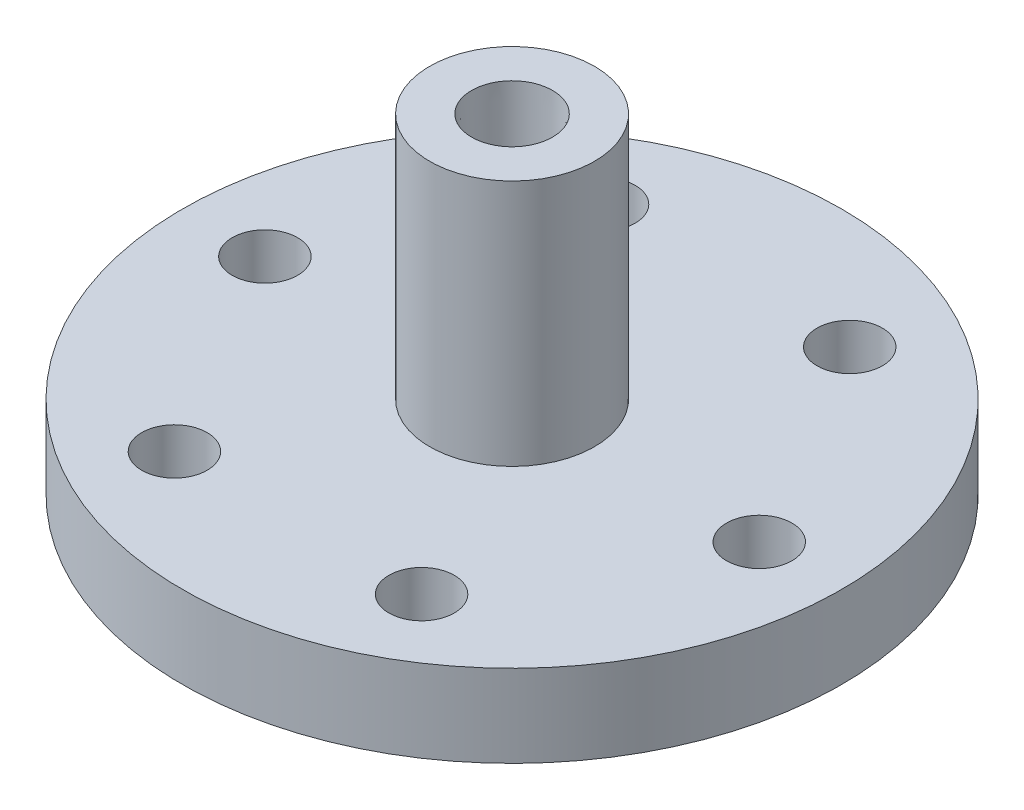
from build123d import *

# Parameters (mm, degrees)
F_3_8_CLEARANCE_HOLE1_D              = 10.0838
CIRPATTERN1_COUNT                    = 6
F_1_32_0_03125_DIAMETER_HOLE1_REACH  = 133.807
F_1_32_0_03125_DIAMETER_HOLE1_BORE_R = 0.396875
F_1_4_0_25_DIAMETER_HOLE1_D          = 6.35
F_1_4_0_25_DIAMETER_HOLE1_DEPTH      = 12.7
F_1_4_0_25_DIAMETER_HOLE1_TIP        = 1.907732465


with BuildPart() as part:
    # Sketch1 → Revolve1 (revolve)
    with BuildSketch(Plane.XY, mode=Mode.PRIVATE) as revolve1_sk:
        Polygon((0, 0), (-12.7, 0), (-12.7, -38.1), (-50.8, -38.1), (-50.8, -50.8), (-13.081, -50.8), (-13.081, -48.26), (-9.525, -48.26), (-9.525, -50.8), (0, -50.8), align=None)
    revolve(revolve1_sk.sketch.rotate(Axis((0, -50.8, 0), (0, 1, 0)), 270), axis=Axis((0, -50.8, 0), (0, 1, 0)))

    # Sketch4 → 1_4 NPT Tapped Hole1 (revolve, cut)
    with BuildSketch(Plane(origin=(0, 0, 0), x_dir=(0, 0, 1), z_dir=(1, 0, 0))):
        Polygon((0, 0), (0, 50.8), (5.5626, 50.8), (5.5626, 9.906), (5.943685794, 9.906), (6.2402847, 0), align=None)
    revolve(axis=Axis((0, 6.35, 0), (0, -1, 0)), mode=Mode.SUBTRACT)

    # 3_8 Clearance Hole1 (through all)
    with Locations(Plane(origin=(0, -38.1, 0), x_dir=(1, 0, 0), z_dir=(0, 1, 0))):
        with Locations((38.1, 0)):
            f_3_8_clearance_hole1 = Hole(F_3_8_CLEARANCE_HOLE1_D / 2)

    # CirPattern1: 3_8 Clearance Hole1 ×6 about axis
    cirpattern1_axis = Axis((0, 0, 0), (0, 1, 0))
    for i in range(1, CIRPATTERN1_COUNT):
        add(f_3_8_clearance_hole1.rotate(cirpattern1_axis, i * 360 / CIRPATTERN1_COUNT), mode=Mode.SUBTRACT)

    # 1_32 _0.03125_ Diameter Hole1 bore → 1_32 _0.03125_ Diameter Hole1 (cut, up to next)
    with BuildSketch(Plane(origin=(-43.994090512, 0, 25.4), x_dir=(0, -1, 0), z_dir=(-0.8660254037844398, 0, 0.499999999999998)), mode=Mode.PRIVATE) as f_1_32_0_03125_diameter_hole1_sk1:
        with Locations((44.45, 0)):
            Circle(F_1_32_0_03125_DIAMETER_HOLE1_BORE_R)
    f_1_32_0_03125_diameter_hole1_tool1 = extrude(f_1_32_0_03125_diameter_hole1_sk1.sketch, amount=-F_1_32_0_03125_DIAMETER_HOLE1_REACH, mode=Mode.PRIVATE) & part.part
    add(f_1_32_0_03125_diameter_hole1_tool1.solids().sort_by_distance((-43.994091, -44.45, 25.4))[0], mode=Mode.SUBTRACT)

    # 1_4 _0.25_ Diameter Hole1
    with Locations(Plane(origin=(-43.994090512, 0, 25.4), x_dir=(0, -1, 0), z_dir=(-0.8660254037844398, 0, 0.499999999999998))):
        with Locations((44.45, 0)):
            Hole(F_1_4_0_25_DIAMETER_HOLE1_D / 2, depth=F_1_4_0_25_DIAMETER_HOLE1_DEPTH)
            with Locations((0, 0, -(F_1_4_0_25_DIAMETER_HOLE1_DEPTH + F_1_4_0_25_DIAMETER_HOLE1_TIP / 2))):  # 118° drill point
                Cone(0, F_1_4_0_25_DIAMETER_HOLE1_D / 2, F_1_4_0_25_DIAMETER_HOLE1_TIP, mode=Mode.SUBTRACT)


solid = part.part
